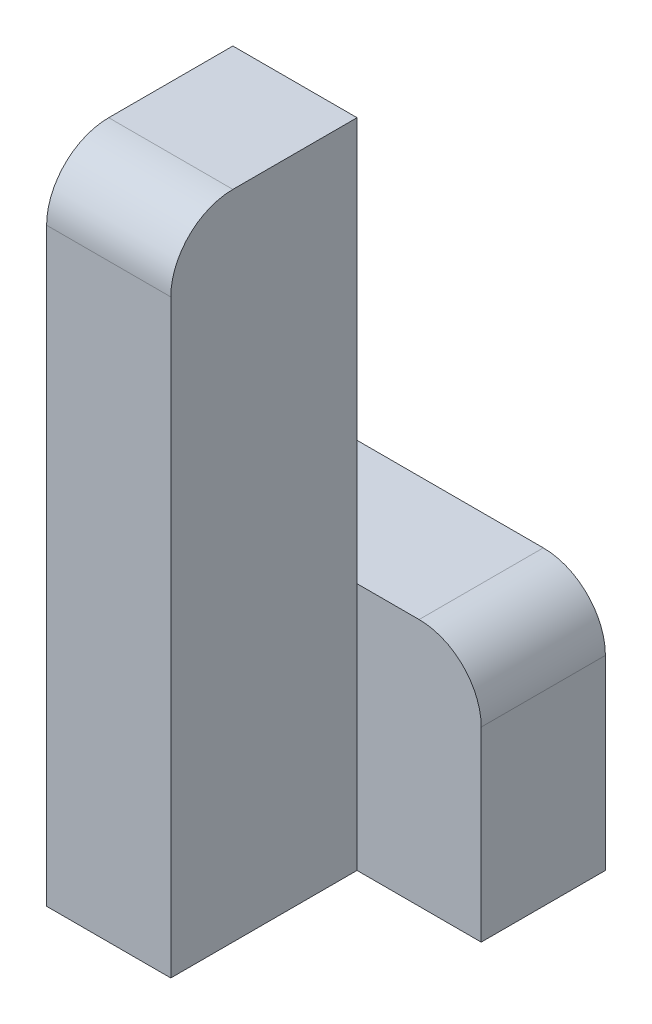
from build123d import *

# Parameters (mm, degrees)
SKETCH1_W           = 20
SKETCH1_H           = 105
BOSS_EXTRUDE1_DEPTH = 30
SKETCH2_W           = 40
SKETCH2_H           = 40
BOSS_EXTRUDE2_DEPTH = 20
FILLET1_R           = 10


with BuildPart() as part:
    # Sketch1 → Boss-Extrude1 (new body)
    with BuildSketch(Plane.XY):
        with Locations((-20, -52.5)):
            Rectangle(SKETCH1_W, SKETCH1_H)
    extrude(amount=BOSS_EXTRUDE1_DEPTH)

    # Sketch2 → Boss-Extrude2 (add)
    with BuildSketch(Plane.XY):
        with Locations((-10, -85)):
            Rectangle(SKETCH2_W, SKETCH2_H)
    extrude(amount=-BOSS_EXTRUDE2_DEPTH)

    # Fillet1
    fillet1_edges = [part.edges().sort_by_distance(p)[0] for p in [
        (10, -65, -10),
        (-20, 0, 30),
    ]]
    fillet(fillet1_edges, radius=FILLET1_R)


solid = part.part
